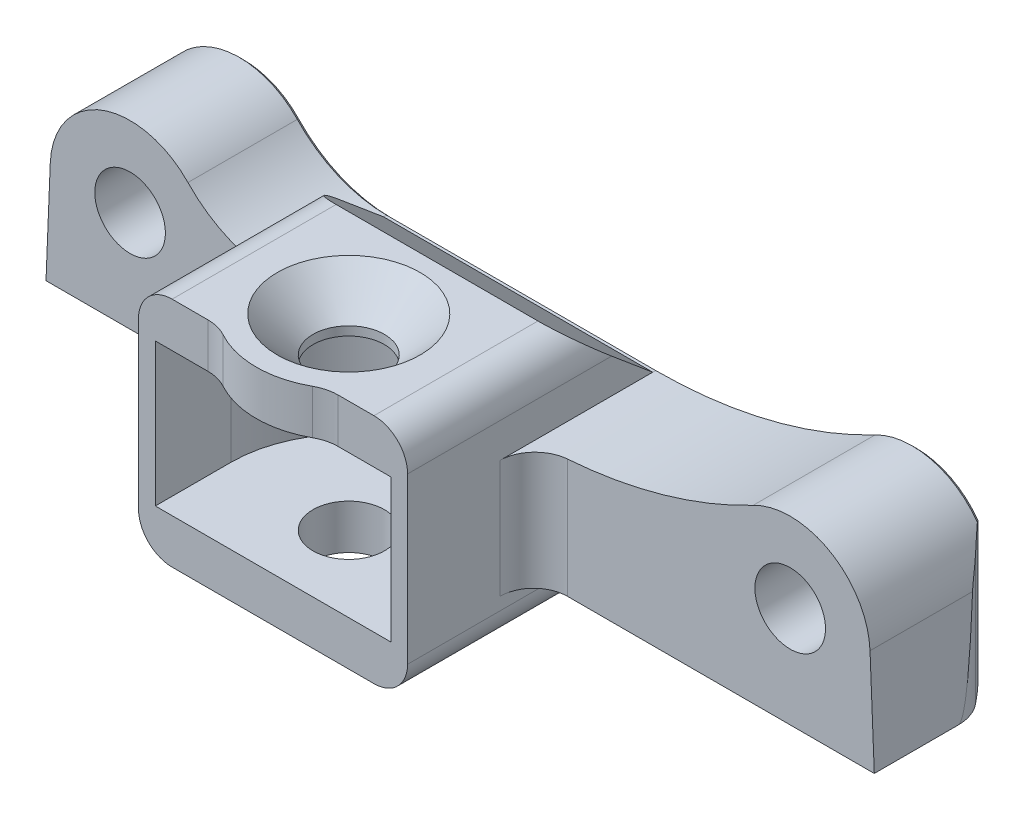
from build123d import *

# Parameters (mm, degrees)
BOSS_EXTRUDE1_DEPTH                             = 16
SKETCH2_R                                       = 4.25
CUT_EXTRUDE1_DEPTH                              = 28.6
CUT_EXTRUDE2_START                              = -5.3
CUT_EXTRUDE2_DEPTH                              = 17
CSK_FOR_M8_FLAT_HEAD_MACHINE_SCREW1_D           = 8
CSK_FOR_M8_FLAT_HEAD_MACHINE_SCREW1_CSINK_D     = 17
CSK_FOR_M8_FLAT_HEAD_MACHINE_SCREW1_CSINK_ANGLE = 90
SKETCH6_R                                       = 4.2
BOSS_EXTRUDE2_DEPTH                             = 15
SKETCH7_R                                       = 4.2
BOSS_EXTRUDE3_DEPTH                             = 4
SKETCH9_R                                       = 2.6
CUT_EXTRUDE3_DEPTH                              = 6
CUT_EXTRUDE4_DEPTH                              = 1.5
FILLET2_R                                       = 4
FILLET3_R                                       = 4
BOSS_EXTRUDE4_DEPTH                             = 5.3
FILLET4_R                                       = 5
CHAMFER1_SIZE                                   = 0.6
CUT_EXTRUDE5_DEPTH                              = 23.1
CHAMFER2_SIZE                                   = 0.5


with BuildPart() as part:
    # Sketch1 → Boss-Extrude1 (new body, symmetric)
    with BuildSketch(Plane(origin=(0, 0, 0), x_dir=(0, 0, -1), z_dir=(1, 0, 0))):
        Polygon((0, 0), (0, 14), (-0.8467959, 14), (-10.5, 22.1), (-30, 22.1), (-30, -5.5), (-11.5, -5.5), (-4.945355241, 0), align=None)
    extrude(amount=BOSS_EXTRUDE1_DEPTH, both=True)

    # Sketch2 → Cut-Extrude1 (cut, through all)
    with BuildSketch(Plane(origin=(0, 22.1, 0), x_dir=(1, 0, 0), z_dir=(0, 1, 0))):
        with Locations(Location((0, -21, 0), (0, 0, 270))):  # turned: the seam where the file's is
            Circle(SKETCH2_R)
    extrude(amount=-CUT_EXTRUDE1_DEPTH, mode=Mode.SUBTRACT)

    # Sketch3 → Cut-Extrude2 (cut)
    with BuildSketch(Plane(origin=(0, 22.1, 0), x_dir=(1, 0, 0), z_dir=(0, 1, 0)).offset(CUT_EXTRUDE2_START)):
        with BuildLine():
            Line((-14, -21), (-14, -59.082734499))
            Line((-14, -59.082734499), (14, -59.082734499))
            Line((14, -59.082734499), (14, -21))
            ThreePointArc((14, -21), (0, -7), (-14, -21))
        make_face()
    extrude(amount=-CUT_EXTRUDE2_DEPTH, mode=Mode.SUBTRACT)

    # CSK for M8 Flat Head Machine Screw1 (through all)
    with Locations(Plane(origin=(0, 22.1, 0), x_dir=(-1, 0, 0), z_dir=(0, 1, 0))):
        with Locations((0, 21)):
            CounterSinkHole(CSK_FOR_M8_FLAT_HEAD_MACHINE_SCREW1_D / 2, CSK_FOR_M8_FLAT_HEAD_MACHINE_SCREW1_CSINK_D / 2, counter_sink_angle=CSK_FOR_M8_FLAT_HEAD_MACHINE_SCREW1_CSINK_ANGLE)

    # Sketch6 → Boss-Extrude2 (add)
    with BuildSketch(Plane(origin=(0, 0, 0), x_dir=(-1, 0, 0), z_dir=(0, 0, -1))):
        with BuildLine():
            Line((-16, 14), (-16, 0))
            Line((-16, 0), (-56.5, 0))
            Line((-56.5, 0), (-55.992024719, 12.389187266))
            ThreePointArc((-55.992024719, 12.389187266), (-51.251583122, 20.226327117), (-42.094272681, 20.41662443))
            ThreePointArc((-42.094272681, 20.41662443), (-29.435811623, 15.627699401), (-16, 14))
        make_face()
        with Locations((-46.5, 12)):
            Circle(SKETCH6_R, mode=Mode.SUBTRACT)
        with BuildLine():
            Line((42.992024719, 12.389187266), (43.5, 0))
            Line((43.5, 0), (16, 0))
            Line((16, 0), (16, 14))
            ThreePointArc((16, 14), (21.777483046, 15.185872893), (26.620689655, 18.551724138))
            ThreePointArc((26.620689655, 18.551724138), (36.846757278, 20.890962587), (42.992024719, 12.389187266))
        make_face()
        with Locations((33.5, 12)):
            Circle(SKETCH6_R, mode=Mode.SUBTRACT)
    extrude(amount=-BOSS_EXTRUDE2_DEPTH)

    # Sketch7 → Boss-Extrude3 (add)
    with BuildSketch(Plane(origin=(0, 0, 0), x_dir=(-1, 0, 0), z_dir=(0, 0, -1))):
        with Locations((-46.5, 12)):
            Circle(SKETCH7_R)
        with Locations((33.5, 12)):
            Circle(SKETCH7_R)
    extrude(amount=-BOSS_EXTRUDE3_DEPTH)

    # Sketch9 → Cut-Extrude3 (cut)
    with BuildSketch(Plane.XZ):
        with Locations(Location((-38.5, 5, 0), (0, 0, 270))):  # turned: the seam where the file's is
            Circle(SKETCH9_R)
        with Locations(Location((-25.5, 10, 0), (0, 0, 270))):  # turned: the seam where the file's is
            Circle(SKETCH9_R)
        with Locations(Location((38.5, 10, 0), (0, 0, 270))):  # turned: the seam where the file's is
            Circle(SKETCH9_R)
        with Locations(Location((51.5, 5, 0), (0, 0, 270))):  # turned: the seam where the file's is
            Circle(SKETCH9_R)
    extrude(amount=-CUT_EXTRUDE3_DEPTH, mode=Mode.SUBTRACT)

    # Sketch11 → Cut-Extrude4 (cut)
    with BuildSketch(Plane.XY.offset(15)):
        with BuildLine():
            Line((-42.992024719, 12.389187266), (-43.5, 0))
            Line((-43.5, 0), (-16, 0))
            Line((-16, 0), (-16, 14))
            ThreePointArc((-16, 14), (-21.777483046, 15.185872893), (-26.620689655, 18.551724138))
            ThreePointArc((-26.620689655, 18.551724138), (-36.846757278, 20.890962587), (-42.992024719, 12.389187266))
        make_face()
    extrude(amount=-CUT_EXTRUDE4_DEPTH, mode=Mode.SUBTRACT)

    # Fillet2
    fillet2_edges = [part.edges().sort_by_distance(p)[0] for p in [
        (-16, 7, 13.5),
        (16, 7, 15),
    ]]
    fillet(fillet2_edges, radius=FILLET2_R)

    # Fillet3
    fillet3_edges = [part.edges().sort_by_distance(p)[0] for p in [
        (16, -5.5, 20.75),
        (-16, -5.5, 20.75),
        (-16, 22.1, 20.25),
        (16, 22.1, 20.25),
    ]]
    fillet(fillet3_edges, radius=FILLET3_R)

    # Sketch10 → Boss-Extrude4 (add)
    with BuildSketch(Plane(origin=(0, 22.1, 0), x_dir=(1, 0, 0), z_dir=(0, 1, 0))):
        with BuildLine():
            Line((6.32455532, -30), (-6.32455532, -30))
            ThreePointArc((-6.32455532, -30), (0, -32), (6.32455532, -30))
        make_face()
    extrude(amount=-BOSS_EXTRUDE4_DEPTH)

    # Fillet4
    fillet4_edges = [part.edges().sort_by_distance(p)[0] for p in [
        (6.32455532, 19.45, 30),
        (-6.32455532, 19.45, 30),
    ]]
    fillet(fillet4_edges, radius=FILLET4_R)

    # Chamfer1
    chamfer1_edges = [part.edges().sort_by_distance(p)[0] for p in [
        (-38.5, 0, 7.6),
        (-25.5, 0, 12.6),
        (38.5, 0, 12.6),
        (51.5, 0, 7.6),
    ]]
    chamfer(chamfer1_edges, length=CHAMFER1_SIZE)

    # Sketch12 → Cut-Extrude5 (cut, through all)
    with BuildSketch(Plane.XZ):
        with BuildLine():
            Line((-42.330222216, 1.786061952), (-40.831538291, 0))
            Line((-40.831538291, 0), (-43.5, 0))
            Line((-43.5, 0), (-43.5, 5))
            ThreePointArc((-43.5, 5), (-43.198463104, 3.289899283), (-42.330222216, 1.786061952))
        make_face()
        with BuildLine():
            Line((55.330222216, 1.786061952), (53.831538291, 0))
            Line((53.831538291, 0), (56.5, 0))
            Line((56.5, 0), (56.5, 5))
            ThreePointArc((56.5, 5), (56.198463104, 3.289899283), (55.330222216, 1.786061952))
        make_face()
    extrude(amount=-CUT_EXTRUDE5_DEPTH, mode=Mode.SUBTRACT)

    # Chamfer2
    chamfer2_edges = [part.edges().sort_by_distance(p)[0] for p in [
        (-33.840931852, 21.493880422, 0),
        (-21.777483046, 15.185872893, 0),
        (0, 14, 0),
        (29.435811623, 15.627699401, 0),
        (48.384280249, 21.311255981, 0),
        (6.5, 0, 0),
    ]]
    chamfer(chamfer2_edges, length=CHAMFER2_SIZE)


solid = part.part
